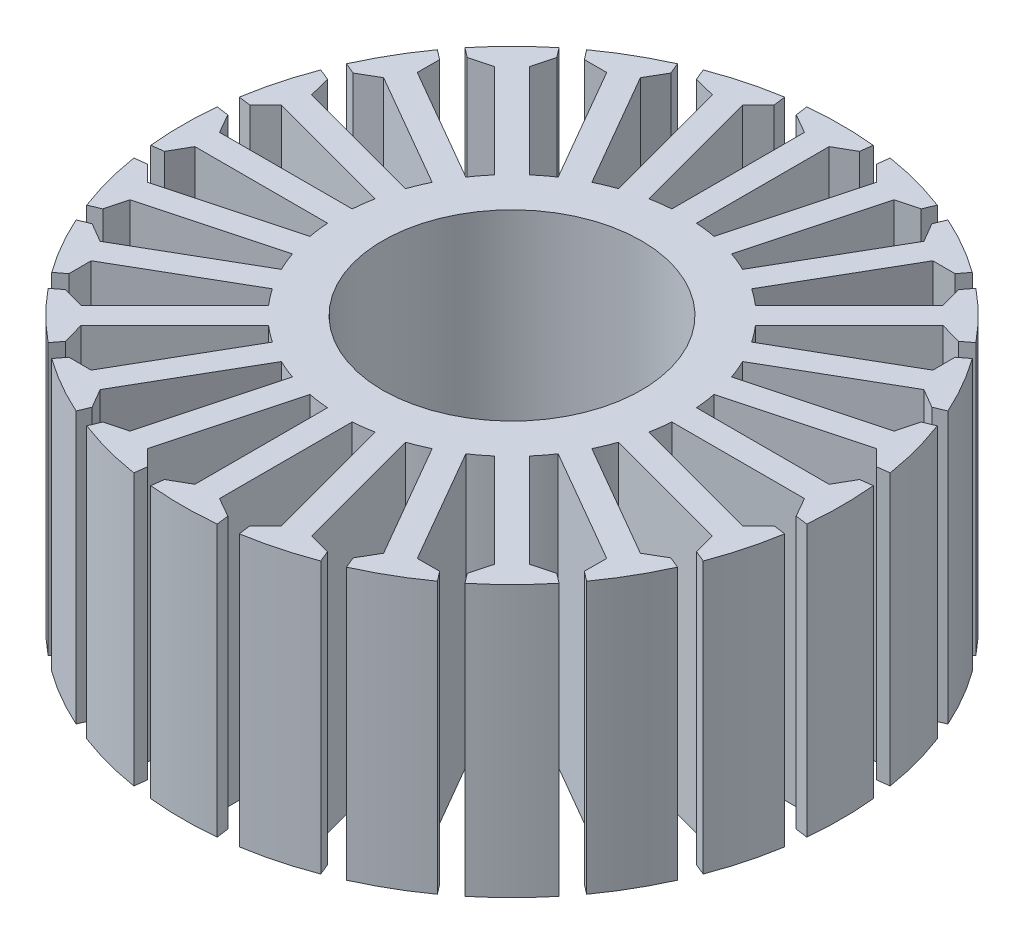
from build123d import *

# Parameters (mm, degrees)
SKETCH5_R           = 10.5
BOSS_EXTRUDE1_DEPTH = 22


with BuildPart() as part:
    # Sketch5 → Boss-Extrude1 (new body)
    with BuildSketch(Plane(origin=(0, 0, 0), x_dir=(1, 0, 0), z_dir=(0, 1, 0))):
        with BuildLine():
            Line((-1, 24.729789728), (-1, 13.964240044))
            ThreePointArc((-1, 13.964240044), (-1.827366691, 13.880228059), (-2.648285447, 13.747239148))
            Line((-2.648285447, 13.747239148), (-5.434614737, 24.145961622))
            Line((-5.434614737, 24.145961622), (-4.151548547, 25.418492807))
            Line((-4.151548547, 25.418492807), (-4.281443911, 26.405146052))
            ThreePointArc((-4.281443911, 26.405146052), (-6.923409456, 25.838515853), (-9.494733835, 25.008249227))
            Line((-9.494733835, 25.008249227), (-9.113899897, 24.08883477))
            Line((-9.113899897, 24.08883477), (-7.366466389, 23.628323532))
            Line((-7.366466389, 23.628323532), (-4.5801371, 13.229601058))
            ThreePointArc((-4.5801371, 13.229601058), (-5.357568053, 12.934313455), (-6.116094618, 12.593386622))
            Line((-6.116094618, 12.593386622), (-11.49886946, 21.916626135))
            Line((-11.49886946, 21.916626135), (-10.588877996, 23.477878837))
            Line((-10.588877996, 23.477878837), (-10.969711934, 24.397293294))
            ThreePointArc((-10.969711934, 24.397293294), (-13.375, 23.166179551), (-15.643819809, 21.698695854))
            Line((-15.643819809, 21.698695854), (-15.038000502, 20.909176761))
            Line((-15.038000502, 20.909176761), (-13.230920268, 20.916626135))
            Line((-13.230920268, 20.916626135), (-7.848145426, 11.593386622))
            ThreePointArc((-7.848145426, 11.593386622), (-8.522660006, 11.106946764), (-9.167102048, 10.58131561))
            Line((-9.167102048, 10.58131561), (-16.779495233, 18.193708795))
            Line((-16.779495233, 18.193708795), (-16.30459291, 19.937286223))
            Line((-16.30459291, 19.937286223), (-16.910412218, 20.726805317))
            ThreePointArc((-16.910412218, 20.726805317), (-18.915106397, 18.915106397), (-20.726805317, 16.910412218))
            Line((-20.726805317, 16.910412218), (-19.937286223, 16.30459291))
            Line((-19.937286223, 16.30459291), (-18.193708795, 16.779495233))
            Line((-18.193708795, 16.779495233), (-10.58131561, 9.167102048))
            ThreePointArc((-10.58131561, 9.167102048), (-11.106946764, 8.522660006), (-11.593386622, 7.848145426))
            Line((-11.593386622, 7.848145426), (-20.916626135, 13.230920268))
            Line((-20.916626135, 13.230920268), (-20.909176761, 15.038000502))
            Line((-20.909176761, 15.038000502), (-21.698695854, 15.643819809))
            ThreePointArc((-21.698695854, 15.643819809), (-23.166179551, 13.375), (-24.397293294, 10.969711934))
            Line((-24.397293294, 10.969711934), (-23.477878837, 10.588877996))
            Line((-23.477878837, 10.588877996), (-21.916626135, 11.49886946))
            Line((-21.916626135, 11.49886946), (-12.593386622, 6.116094618))
            ThreePointArc((-12.593386622, 6.116094618), (-12.934313455, 5.357568053), (-13.229601058, 4.5801371))
            Line((-13.229601058, 4.5801371), (-23.628323532, 7.366466389))
            Line((-23.628323532, 7.366466389), (-24.08883477, 9.113899897))
            Line((-24.08883477, 9.113899897), (-25.008249227, 9.494733835))
            ThreePointArc((-25.008249227, 9.494733835), (-25.838515853, 6.923409456), (-26.405146052, 4.281443911))
            Line((-26.405146052, 4.281443911), (-25.418492807, 4.151548547))
            Line((-25.418492807, 4.151548547), (-24.145961622, 5.434614737))
            Line((-24.145961622, 5.434614737), (-13.747239148, 2.648285447))
            ThreePointArc((-13.747239148, 2.648285447), (-13.880228059, 1.827366691), (-13.964240044, 1))
            Line((-13.964240044, 1), (-24.729789728, 1))
            Line((-24.729789728, 1), (-25.626878498, 2.568702076))
            Line((-25.626878498, 2.568702076), (-26.613531743, 2.69859744))
            ThreePointArc((-26.613531743, 2.69859744), (-26.75, 0), (-26.613531743, -2.69859744))
            Line((-26.613531743, -2.69859744), (-25.626878498, -2.568702076))
            Line((-25.626878498, -2.568702076), (-24.729789728, -1))
            Line((-24.729789728, -1), (-13.964240044, -1))
            ThreePointArc((-13.964240044, -1), (-13.880228059, -1.827366691), (-13.747239148, -2.648285447))
            Line((-13.747239148, -2.648285447), (-24.145961622, -5.434614737))
            Line((-24.145961622, -5.434614737), (-25.418492807, -4.151548547))
            Line((-25.418492807, -4.151548547), (-26.405146052, -4.281443911))
            ThreePointArc((-26.405146052, -4.281443911), (-25.838515853, -6.923409456), (-25.008249227, -9.494733835))
            Line((-25.008249227, -9.494733835), (-24.08883477, -9.113899897))
            Line((-24.08883477, -9.113899897), (-23.628323532, -7.366466389))
            Line((-23.628323532, -7.366466389), (-13.229601058, -4.5801371))
            ThreePointArc((-13.229601058, -4.5801371), (-12.934313455, -5.357568053), (-12.593386622, -6.116094618))
            Line((-12.593386622, -6.116094618), (-21.916626135, -11.49886946))
            Line((-21.916626135, -11.49886946), (-23.477878837, -10.588877996))
            Line((-23.477878837, -10.588877996), (-24.397293294, -10.969711934))
            ThreePointArc((-24.397293294, -10.969711934), (-23.166179551, -13.375), (-21.698695854, -15.643819809))
            Line((-21.698695854, -15.643819809), (-20.909176761, -15.038000502))
            Line((-20.909176761, -15.038000502), (-20.916626135, -13.230920268))
            Line((-20.916626135, -13.230920268), (-11.593386622, -7.848145426))
            ThreePointArc((-11.593386622, -7.848145426), (-11.106946764, -8.522660006), (-10.58131561, -9.167102048))
            Line((-10.58131561, -9.167102048), (-18.193708795, -16.779495233))
            Line((-18.193708795, -16.779495233), (-19.937286223, -16.30459291))
            Line((-19.937286223, -16.30459291), (-20.726805317, -16.910412218))
            ThreePointArc((-20.726805317, -16.910412218), (-18.915106397, -18.915106397), (-16.910412218, -20.726805317))
            Line((-16.910412218, -20.726805317), (-16.30459291, -19.937286223))
            Line((-16.30459291, -19.937286223), (-16.779495233, -18.193708795))
            Line((-16.779495233, -18.193708795), (-9.167102048, -10.58131561))
            ThreePointArc((-9.167102048, -10.58131561), (-8.522660006, -11.106946764), (-7.848145426, -11.593386622))
            Line((-7.848145426, -11.593386622), (-13.230920268, -20.916626135))
            Line((-13.230920268, -20.916626135), (-15.038000502, -20.909176761))
            Line((-15.038000502, -20.909176761), (-15.643819809, -21.698695854))
            ThreePointArc((-15.643819809, -21.698695854), (-13.375, -23.166179551), (-10.969711934, -24.397293294))
            Line((-10.969711934, -24.397293294), (-10.588877996, -23.477878837))
            Line((-10.588877996, -23.477878837), (-11.49886946, -21.916626135))
            Line((-11.49886946, -21.916626135), (-6.116094618, -12.593386622))
            ThreePointArc((-6.116094618, -12.593386622), (-5.357568053, -12.934313455), (-4.5801371, -13.229601058))
            Line((-4.5801371, -13.229601058), (-7.366466389, -23.628323532))
            Line((-7.366466389, -23.628323532), (-9.113899897, -24.08883477))
            Line((-9.113899897, -24.08883477), (-9.494733835, -25.008249227))
            ThreePointArc((-9.494733835, -25.008249227), (-6.923409456, -25.838515853), (-4.281443911, -26.405146052))
            Line((-4.281443911, -26.405146052), (-4.151548547, -25.418492807))
            Line((-4.151548547, -25.418492807), (-5.434614737, -24.145961622))
            Line((-5.434614737, -24.145961622), (-2.648285447, -13.747239148))
            ThreePointArc((-2.648285447, -13.747239148), (-1.827366691, -13.880228059), (-1, -13.964240044))
            Line((-1, -13.964240044), (-1, -24.729789728))
            Line((-1, -24.729789728), (-2.568702076, -25.626878498))
            Line((-2.568702076, -25.626878498), (-2.69859744, -26.613531743))
            ThreePointArc((-2.69859744, -26.613531743), (0, -26.75), (2.69859744, -26.613531743))
            Line((2.69859744, -26.613531743), (2.568702076, -25.626878498))
            Line((2.568702076, -25.626878498), (1, -24.729789728))
            Line((1, -24.729789728), (1, -13.964240044))
            ThreePointArc((1, -13.964240044), (1.827366691, -13.880228059), (2.648285447, -13.747239148))
            Line((2.648285447, -13.747239148), (5.434614737, -24.145961622))
            Line((5.434614737, -24.145961622), (4.151548547, -25.418492807))
            Line((4.151548547, -25.418492807), (4.281443911, -26.405146052))
            ThreePointArc((4.281443911, -26.405146052), (6.923409456, -25.838515853), (9.494733835, -25.008249227))
            Line((9.494733835, -25.008249227), (9.113899897, -24.08883477))
            Line((9.113899897, -24.08883477), (7.366466389, -23.628323532))
            Line((7.366466389, -23.628323532), (4.5801371, -13.229601058))
            ThreePointArc((4.5801371, -13.229601058), (5.357568053, -12.934313455), (6.116094618, -12.593386622))
            Line((6.116094618, -12.593386622), (11.49886946, -21.916626135))
            Line((11.49886946, -21.916626135), (10.588877996, -23.477878837))
            Line((10.588877996, -23.477878837), (10.969711934, -24.397293294))
            ThreePointArc((10.969711934, -24.397293294), (13.375, -23.166179551), (15.643819809, -21.698695854))
            Line((15.643819809, -21.698695854), (15.038000502, -20.909176761))
            Line((15.038000502, -20.909176761), (13.230920268, -20.916626135))
            Line((13.230920268, -20.916626135), (7.848145426, -11.593386622))
            ThreePointArc((7.848145426, -11.593386622), (8.522660006, -11.106946764), (9.167102048, -10.58131561))
            Line((9.167102048, -10.58131561), (16.779495233, -18.193708795))
            Line((16.779495233, -18.193708795), (16.30459291, -19.937286223))
            Line((16.30459291, -19.937286223), (16.910412218, -20.726805317))
            ThreePointArc((16.910412218, -20.726805317), (18.915106397, -18.915106397), (20.726805317, -16.910412218))
            Line((20.726805317, -16.910412218), (19.937286223, -16.30459291))
            Line((19.937286223, -16.30459291), (18.193708795, -16.779495233))
            Line((18.193708795, -16.779495233), (10.58131561, -9.167102048))
            ThreePointArc((10.58131561, -9.167102048), (11.106946764, -8.522660006), (11.593386622, -7.848145426))
            Line((11.593386622, -7.848145426), (20.916626135, -13.230920268))
            Line((20.916626135, -13.230920268), (20.909176761, -15.038000502))
            Line((20.909176761, -15.038000502), (21.698695854, -15.643819809))
            ThreePointArc((21.698695854, -15.643819809), (23.166179551, -13.375), (24.397293294, -10.969711934))
            Line((24.397293294, -10.969711934), (23.477878837, -10.588877996))
            Line((23.477878837, -10.588877996), (21.916626135, -11.49886946))
            Line((21.916626135, -11.49886946), (12.593386622, -6.116094618))
            ThreePointArc((12.593386622, -6.116094618), (12.934313455, -5.357568053), (13.229601058, -4.5801371))
            Line((13.229601058, -4.5801371), (23.628323532, -7.366466389))
            Line((23.628323532, -7.366466389), (24.08883477, -9.113899897))
            Line((24.08883477, -9.113899897), (25.008249227, -9.494733835))
            ThreePointArc((25.008249227, -9.494733835), (25.838515853, -6.923409456), (26.405146052, -4.281443911))
            Line((26.405146052, -4.281443911), (25.418492807, -4.151548547))
            Line((25.418492807, -4.151548547), (24.145961622, -5.434614737))
            Line((24.145961622, -5.434614737), (13.747239148, -2.648285447))
            ThreePointArc((13.747239148, -2.648285447), (13.880228059, -1.827366691), (13.964240044, -1))
            Line((13.964240044, -1), (24.729789728, -1))
            Line((24.729789728, -1), (25.626878498, -2.568702076))
            Line((25.626878498, -2.568702076), (26.613531743, -2.69859744))
            ThreePointArc((26.613531743, -2.69859744), (26.75, 0), (26.613531743, 2.69859744))
            Line((26.613531743, 2.69859744), (25.626878498, 2.568702076))
            Line((25.626878498, 2.568702076), (24.729789728, 1))
            Line((24.729789728, 1), (13.964240044, 1))
            ThreePointArc((13.964240044, 1), (13.880228059, 1.827366691), (13.747239148, 2.648285447))
            Line((13.747239148, 2.648285447), (24.145961622, 5.434614737))
            Line((24.145961622, 5.434614737), (25.418492807, 4.151548547))
            Line((25.418492807, 4.151548547), (26.405146052, 4.281443911))
            ThreePointArc((26.405146052, 4.281443911), (25.838515853, 6.923409456), (25.008249227, 9.494733835))
            Line((25.008249227, 9.494733835), (24.08883477, 9.113899897))
            Line((24.08883477, 9.113899897), (23.628323532, 7.366466389))
            Line((23.628323532, 7.366466389), (13.229601058, 4.5801371))
            ThreePointArc((13.229601058, 4.5801371), (12.934313455, 5.357568053), (12.593386622, 6.116094618))
            Line((12.593386622, 6.116094618), (21.916626135, 11.49886946))
            Line((21.916626135, 11.49886946), (23.477878837, 10.588877996))
            Line((23.477878837, 10.588877996), (24.397293294, 10.969711934))
            ThreePointArc((24.397293294, 10.969711934), (23.166179551, 13.375), (21.698695854, 15.643819809))
            Line((21.698695854, 15.643819809), (20.909176761, 15.038000502))
            Line((20.909176761, 15.038000502), (20.916626135, 13.230920268))
            Line((20.916626135, 13.230920268), (11.593386622, 7.848145426))
            ThreePointArc((11.593386622, 7.848145426), (11.106946764, 8.522660006), (10.58131561, 9.167102048))
            Line((10.58131561, 9.167102048), (18.193708795, 16.779495233))
            Line((18.193708795, 16.779495233), (19.937286223, 16.30459291))
            Line((19.937286223, 16.30459291), (20.726805317, 16.910412218))
            ThreePointArc((20.726805317, 16.910412218), (18.915106397, 18.915106397), (16.910412218, 20.726805317))
            Line((16.910412218, 20.726805317), (16.30459291, 19.937286223))
            Line((16.30459291, 19.937286223), (16.779495233, 18.193708795))
            Line((16.779495233, 18.193708795), (9.167102048, 10.58131561))
            ThreePointArc((9.167102048, 10.58131561), (8.522660006, 11.106946764), (7.848145426, 11.593386622))
            Line((7.848145426, 11.593386622), (13.230920268, 20.916626135))
            Line((13.230920268, 20.916626135), (15.038000502, 20.909176761))
            Line((15.038000502, 20.909176761), (15.643819809, 21.698695854))
            ThreePointArc((15.643819809, 21.698695854), (13.375, 23.166179551), (10.969711934, 24.397293294))
            Line((10.969711934, 24.397293294), (10.588877996, 23.477878837))
            Line((10.588877996, 23.477878837), (11.49886946, 21.916626135))
            Line((11.49886946, 21.916626135), (6.116094618, 12.593386622))
            ThreePointArc((6.116094618, 12.593386622), (5.357568053, 12.934313455), (4.5801371, 13.229601058))
            Line((4.5801371, 13.229601058), (7.366466389, 23.628323532))
            Line((7.366466389, 23.628323532), (9.113899897, 24.08883477))
            Line((9.113899897, 24.08883477), (9.494733835, 25.008249227))
            ThreePointArc((9.494733835, 25.008249227), (6.923409456, 25.838515853), (4.281443911, 26.405146052))
            Line((4.281443911, 26.405146052), (4.151548547, 25.418492807))
            Line((4.151548547, 25.418492807), (5.434614737, 24.145961622))
            Line((5.434614737, 24.145961622), (2.648285447, 13.747239148))
            ThreePointArc((2.648285447, 13.747239148), (1.827366691, 13.880228059), (1, 13.964240044))
            Line((1, 13.964240044), (1, 24.729789728))
            Line((1, 24.729789728), (2.568702076, 25.626878498))
            Line((2.568702076, 25.626878498), (2.69859744, 26.613531743))
            ThreePointArc((2.69859744, 26.613531743), (0, 26.75), (-2.69859744, 26.613531743))
            Line((-2.69859744, 26.613531743), (-2.568702076, 25.626878498))
            Line((-2.568702076, 25.626878498), (-1, 24.729789728))
        make_face()
        Circle(SKETCH5_R, mode=Mode.SUBTRACT)
    extrude(amount=BOSS_EXTRUDE1_DEPTH)


solid = part.part
